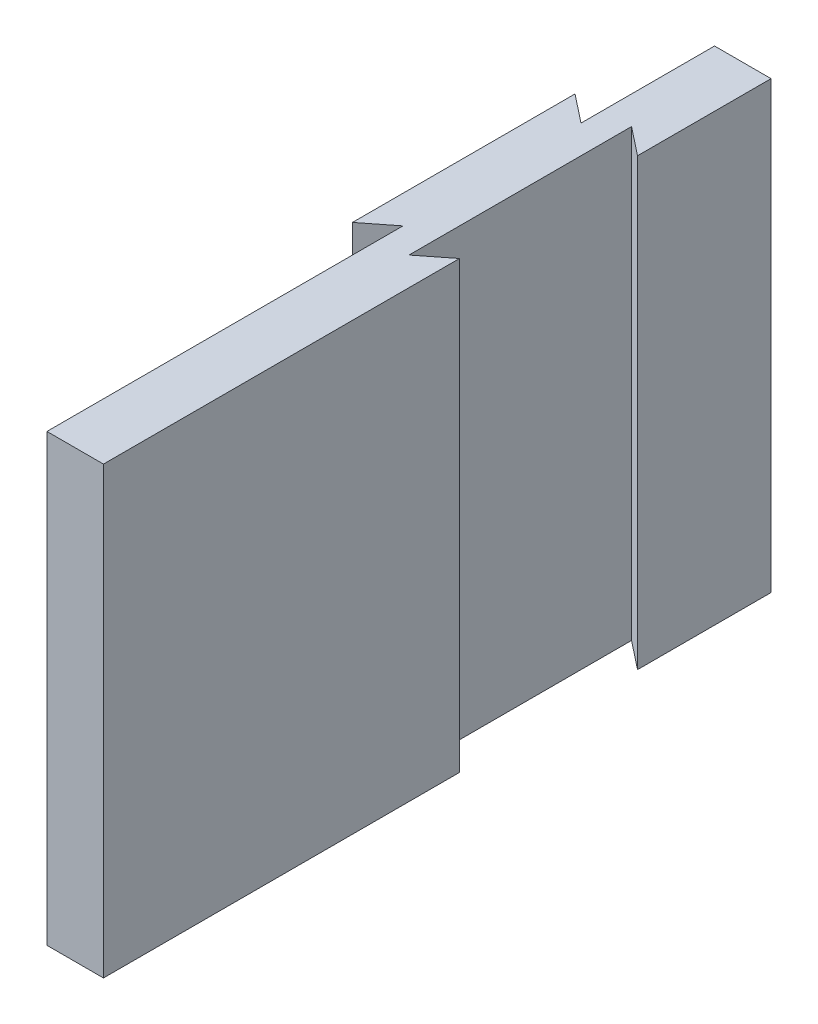
from build123d import *

# Parameters (mm, degrees)
BOSS_EXTRUDE1_DEPTH = 20


with BuildPart() as part:
    # Sketch1 → Boss-Extrude1 (new body)
    with BuildSketch(Plane(origin=(0, 0, 0), x_dir=(1, 0, 0), z_dir=(0, 1, 0))):
        Polygon((0, 5), (1.27, 4), (1.27, 10), (-1.27, 10), (-1.27, 4), (-1.27, -4), (-1.27, -20), (1.27, -20), (1.27, -5), (1.27, -4), (0, -5), align=None)
        Polygon((-2.54, 5), (-2.54, -5), (-1.27, -4), (-1.27, 4), align=None)
    extrude(amount=BOSS_EXTRUDE1_DEPTH)


solid = part.part
